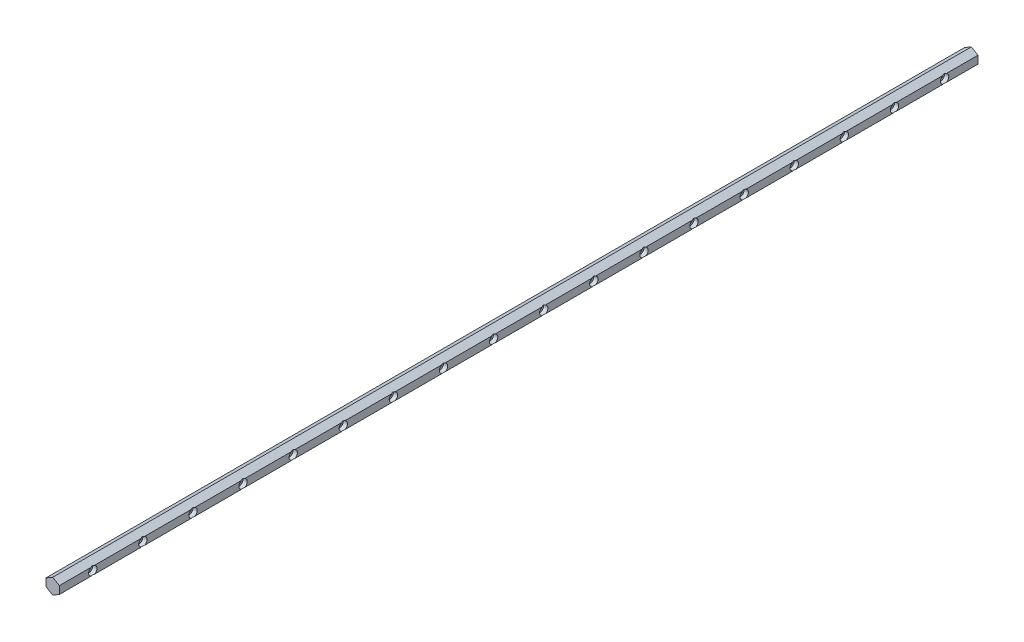
from build123d import *

# Parameters (mm, degrees)
BOSS_EXTRUDE1_DEPTH                             = 1100
CBORE_FOR_M5_SOCKET_HEAD_CAP_SCREW1_D           = 5.5
CBORE_FOR_M5_SOCKET_HEAD_CAP_SCREW1_CBORE_D     = 10
CBORE_FOR_M5_SOCKET_HEAD_CAP_SCREW1_CBORE_DEPTH = 5
LPATTERN1_COUNT                                 = 18
LPATTERN1_PITCH                                 = 60


with BuildPart() as part:
    # Sketch1 → Boss-Extrude1 (new body)
    with BuildSketch(Plane.XY):
        Polygon((0, -9.237604307), (8, -4.618802154), (8, 4.618802154), (0, 9.237604307), (-8, 4.618802154), (-8, -4.618802154), align=None)
    extrude(amount=BOSS_EXTRUDE1_DEPTH)

    # CBORE for M5 Socket Head Cap Screw1 (through all)
    with Locations(Plane(origin=(8, 0, 1060), x_dir=(0, 1, 0), z_dir=(1, 0, 0))):
        with Locations((0, 0)):
            cbore_for_m5_socket_head_cap_screw1 = CounterBoreHole(CBORE_FOR_M5_SOCKET_HEAD_CAP_SCREW1_D / 2, CBORE_FOR_M5_SOCKET_HEAD_CAP_SCREW1_CBORE_D / 2, CBORE_FOR_M5_SOCKET_HEAD_CAP_SCREW1_CBORE_DEPTH)

    # LPattern1: CBORE for M5 Socket Head Cap Screw1 ×18
    with Locations(*[(0, 0, -i * LPATTERN1_PITCH) for i in range(1, LPATTERN1_COUNT)]):
        add(cbore_for_m5_socket_head_cap_screw1, mode=Mode.SUBTRACT)


solid = part.part
